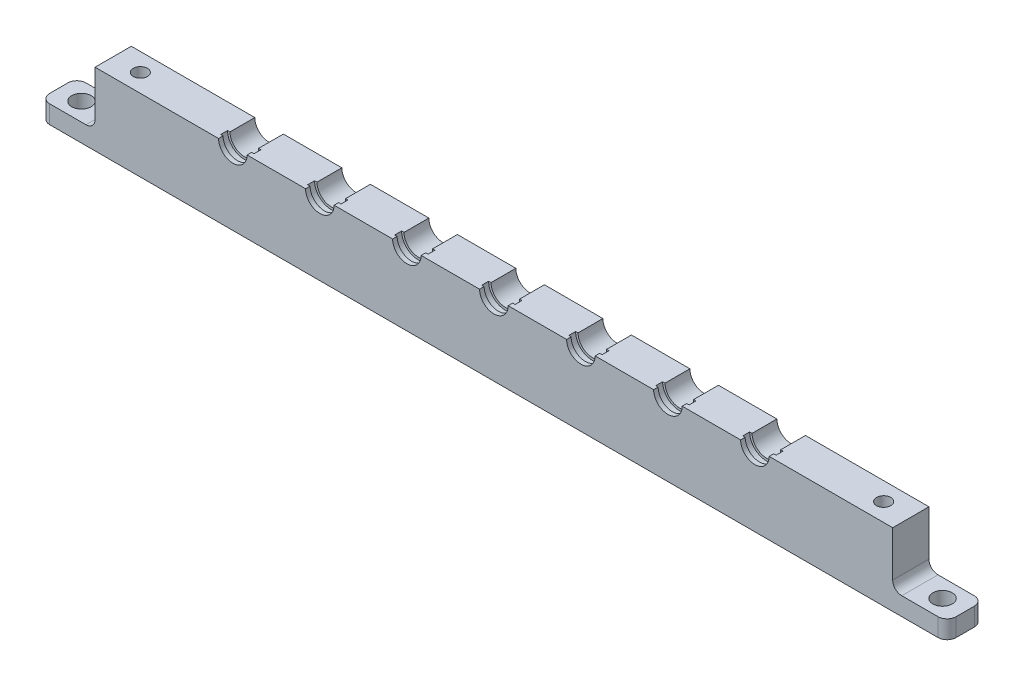
from build123d import *

# Parameters (mm, degrees)
SKETCH1_W                   = 139.7
SKETCH1_H                   = 12.7
BOSS_EXTRUDE1_DEPTH         = 6.35
TAP_DRILL_FOR_M3X0_5_TAP1_D = 2.5
SKETCH5_W                   = 9.525
SKETCH5_H                   = 6.35
BOSS_EXTRUDE2_DEPTH         = 3.175
FILLET1_R                   = 1.5875
M3_CLEARANCE_HOLE1_D        = 3.4
FILLET2_R                   = 1.5875
FILLET2_OF_MIRROR5_R        = 1.5875
FILLET3_R                   = 1.5875
SKETCH14_R                  = 2.5
CUT_EXTRUDE2_DEPTH          = 0.79375
SKETCH15_R                  = 2.921
CUT_EXTRUDE3_DEPTH          = 1.2065
CUT_EXTRUDE4_START          = -5.34975
CUT_EXTRUDE4_DEPTH          = 8.35
LPATTERN1_COUNT             = 4
LPATTERN1_PITCH             = 15.24
LPATTERN2_COUNT             = 4
LPATTERN2_PITCH             = 15.24


with BuildPart() as part:
    # Sketch1 → Boss-Extrude1 (new body)
    with BuildSketch(Plane.XY):
        Rectangle(SKETCH1_W, SKETCH1_H)
    extrude(amount=BOSS_EXTRUDE1_DEPTH)

    # Tap Drill for M3x0.5 Tap1 (through all)
    with Locations(Plane(origin=(0, 6.35, 0), x_dir=(1, 0, 0), z_dir=(0, 1, 0))):
        with Locations((-65.0875, -3.175), (65.0875, -3.175)):
            Hole(TAP_DRILL_FOR_M3X0_5_TAP1_D / 2)

    # Sketch5 → Boss-Extrude2 (add)
    with BuildSketch(Plane.XZ.offset(6.35)):
        with Locations((-74.6125, 3.175)):
            Rectangle(SKETCH5_W, SKETCH5_H)
    boss_extrude2 = extrude(amount=-BOSS_EXTRUDE2_DEPTH)

    # Fillet1
    fillet1_edges = [part.edges().sort_by_distance(p)[0] for p in [
        (-69.85, -3.175, 3.175),
    ]]
    fillet(fillet1_edges, radius=FILLET1_R)

    # M3 Clearance Hole1 (through all)
    with Locations(Plane(origin=(0, -3.175, 0), x_dir=(1, 0, 0), z_dir=(0, 1, 0))):
        with Locations((-75.40625, -3.175)):
            m3_clearance_hole1 = Hole(M3_CLEARANCE_HOLE1_D / 2)

    # Fillet2
    fillet2_edges = [part.edges().sort_by_distance(p)[0] for p in [
        (-79.375, -4.7625, 0),
        (-79.375, -4.7625, 6.35),
    ]]
    fillet(fillet2_edges, radius=FILLET2_R)

    # Mirror5: Boss-Extrude2, M3 Clearance Hole1 across plane
    add(boss_extrude2.mirror(Plane(origin=(0, 0, 0), x_dir=(0, 0, 1), z_dir=(1, 0, 0))))
    add(m3_clearance_hole1.mirror(Plane(origin=(0, 0, 0), x_dir=(0, 0, 1), z_dir=(1, 0, 0))), mode=Mode.SUBTRACT)

    # Fillet2 of Mirror5
    fillet2_of_mirror5_edges = [part.edges().sort_by_distance(p)[0] for p in [
        (79.375, -4.7625, 0),
        (79.375, -4.7625, 6.35),
    ]]
    fillet(fillet2_of_mirror5_edges, radius=FILLET2_OF_MIRROR5_R)

    # Fillet3
    fillet3_edges = [part.edges().sort_by_distance(p)[0] for p in [
        (69.85, -3.175, 3.175),
    ]]
    fillet(fillet3_edges, radius=FILLET3_R)

    # Sketch14 → Cut-Extrude2 (cut)
    with BuildSketch(Plane.XY.offset(6.35)):
        with Locations((0, 6.35)):
            Circle(SKETCH14_R)
    cut_extrude2 = extrude(amount=-CUT_EXTRUDE2_DEPTH, mode=Mode.SUBTRACT)

    # Sketch15 → Cut-Extrude3 (cut)
    with BuildSketch(Plane.XY.offset(5.55625)):
        with Locations((0, 6.35)):
            Circle(SKETCH15_R)
    cut_extrude3 = extrude(amount=-CUT_EXTRUDE3_DEPTH, mode=Mode.SUBTRACT)

    # Sketch16 → Cut-Extrude4 (cut)
    with BuildSketch(Plane.XY.offset(4.34975).offset(CUT_EXTRUDE4_START)):
        with BuildLine():
            Line((-2.5, 182.058245118), (-2.5, 6.35))
            ThreePointArc((-2.5, 6.35), (0, 3.85), (2.5, 6.35))
            Line((2.5, 6.35), (2.5, 182.058245118))
            Line((2.5, 182.058245118), (2.5, 533.474735353))
            Line((2.5, 533.474735353), (-2.5, 533.474735353))
            Line((-2.5, 533.474735353), (-2.5, 182.058245118))
        make_face()
    cut_extrude4 = extrude(amount=CUT_EXTRUDE4_DEPTH, mode=Mode.SUBTRACT)

    # LPattern1: Cut-Extrude2, Cut-Extrude3, Cut-Extrude4 ×4
    with Locations(*[(i * LPATTERN1_PITCH, 0, 0) for i in range(1, LPATTERN1_COUNT)]):
        add(cut_extrude2, mode=Mode.SUBTRACT)
        add(cut_extrude3, mode=Mode.SUBTRACT)
        add(cut_extrude4, mode=Mode.SUBTRACT)

    # LPattern2: Cut-Extrude2, Cut-Extrude3, Cut-Extrude4 ×4
    with Locations(*[(-i * LPATTERN2_PITCH, 0, 0) for i in range(1, LPATTERN2_COUNT)]):
        add(cut_extrude2, mode=Mode.SUBTRACT)
        add(cut_extrude3, mode=Mode.SUBTRACT)
        add(cut_extrude4, mode=Mode.SUBTRACT)


solid = part.part
